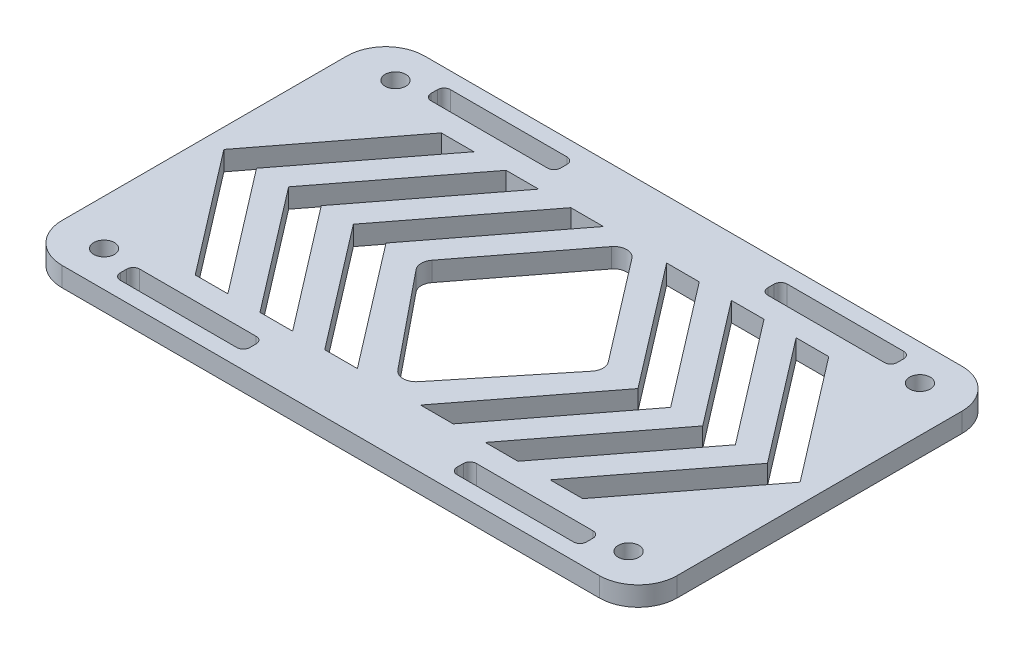
from build123d import *

# Parameters (mm, degrees)
SKETCH_1_W          = 95
SKETCH_1_H          = 56
SKETCH_1_R          = 1.6
EXTRUDE_1_DEPTH     = 3
FILLET_1_R          = 6
SKETCH_2_W          = 20
SKETCH_2_H          = 3
CUT_EXTRUDE_1_DEPTH = 4
FILLET_2_R          = 2
FILLET_3_R          = 1


with BuildPart() as part:
    # 草图1 → 凸台-拉伸1 (new body)
    with BuildSketch(Plane(origin=(0, 0, 0), x_dir=(1, 0, 0), z_dir=(0, 1, 0))):
        Rectangle(SKETCH_1_W, SKETCH_1_H)
        with Locations((-40.5, 22.5)):
            Circle(SKETCH_1_R, mode=Mode.SUBTRACT)
        with Locations((-40.5, -22.5)):
            Circle(SKETCH_1_R, mode=Mode.SUBTRACT)
        with Locations((40.5, -22.5)):
            Circle(SKETCH_1_R, mode=Mode.SUBTRACT)
        with Locations((40.5, 22.5)):
            Circle(SKETCH_1_R, mode=Mode.SUBTRACT)
    extrude(amount=EXTRUDE_1_DEPTH)

    # 圆角1
    fillet_1_edges = [part.edges().sort_by_distance(p)[0] for p in [
        (47.5, 1.5, 28),
        (-47.5, 1.5, 28),
        (-47.5, 1.5, -28),
        (47.5, 1.5, -28),
    ]]
    fillet(fillet_1_edges, radius=FILLET_1_R)

    # 草图2 → 切除-拉伸1 (cut, through all)
    with BuildSketch(Plane(origin=(0, 3, 0), x_dir=(1, 0, 0), z_dir=(0, 1, 0))):
        with Locations((26, 24)):
            Rectangle(SKETCH_2_W, SKETCH_2_H)
        with Locations((-26, 24)):
            Rectangle(SKETCH_2_W, SKETCH_2_H)
        with Locations((-26, -24)):
            Rectangle(SKETCH_2_W, SKETCH_2_H)
        with Locations((26, -24)):
            Rectangle(SKETCH_2_W, SKETCH_2_H)
        Polygon((-39.458110344, 0), (-24.878897572, 19), (-29.920787228, 19), (-44.5, 0), (-29.920787228, -19), (-24.878897572, -19), align=None)
        Polygon((-19.920787228, -19), (-14.878897572, -19), (-29.458110344, 0), (-14.878897572, 19), (-19.920787228, 19), (-34.5, 0), align=None)
        Polygon((-9.920787228, -19), (-4.878897572, -19), (-19.458110344, 0), (-4.878897572, 19), (-9.920787228, 19), (-24.5, 0), align=None)
        Polygon((44.5, 0), (29.920787228, -19), (24.878897572, -19), (39.458110344, 0), (24.878897572, 19), (29.920787228, 19), align=None)
        Polygon((34.5, 0), (19.920787228, -19), (14.878897572, -19), (29.458110344, 0), (14.878897572, 19), (19.920787228, 19), align=None)
        Polygon((24.5, 0), (9.920787228, -19), (4.878897572, -19), (19.458110344, 0), (4.878897572, 19), (9.920787228, 19), align=None)
        Polygon((-14.579212772, 0), (0, 19), (14.579212772, 0), (0, -18), align=None)
    extrude(amount=-CUT_EXTRUDE_1_DEPTH, mode=Mode.SUBTRACT)

    # 圆角2
    fillet_2_edges = [part.edges().sort_by_distance(p)[0] for p in [
        (0, 1.5, 18),
        (-14.579212772, 1.5, 0),
        (0, 1.5, -19),
        (14.579212772, 1.5, 0),
    ]]
    fillet(fillet_2_edges, radius=FILLET_2_R)

    # 圆角3
    fillet_3_edges = [part.edges().sort_by_distance(p)[0] for p in [
        (36, 1.5, -25.5),
        (36, 1.5, -22.5),
        (16, 1.5, -22.5),
        (16, 1.5, -25.5),
        (-36, 1.5, 25.5),
        (-36, 1.5, 22.5),
        (-16, 1.5, 22.5),
        (-16, 1.5, 25.5),
        (16, 1.5, 22.5),
        (36, 1.5, 22.5),
        (36, 1.5, 25.5),
        (16, 1.5, 25.5),
        (-16, 1.5, -25.5),
        (-16, 1.5, -22.5),
        (-36, 1.5, -22.5),
        (-36, 1.5, -25.5),
    ]]
    fillet(fillet_3_edges, radius=FILLET_3_R)


solid = part.part
